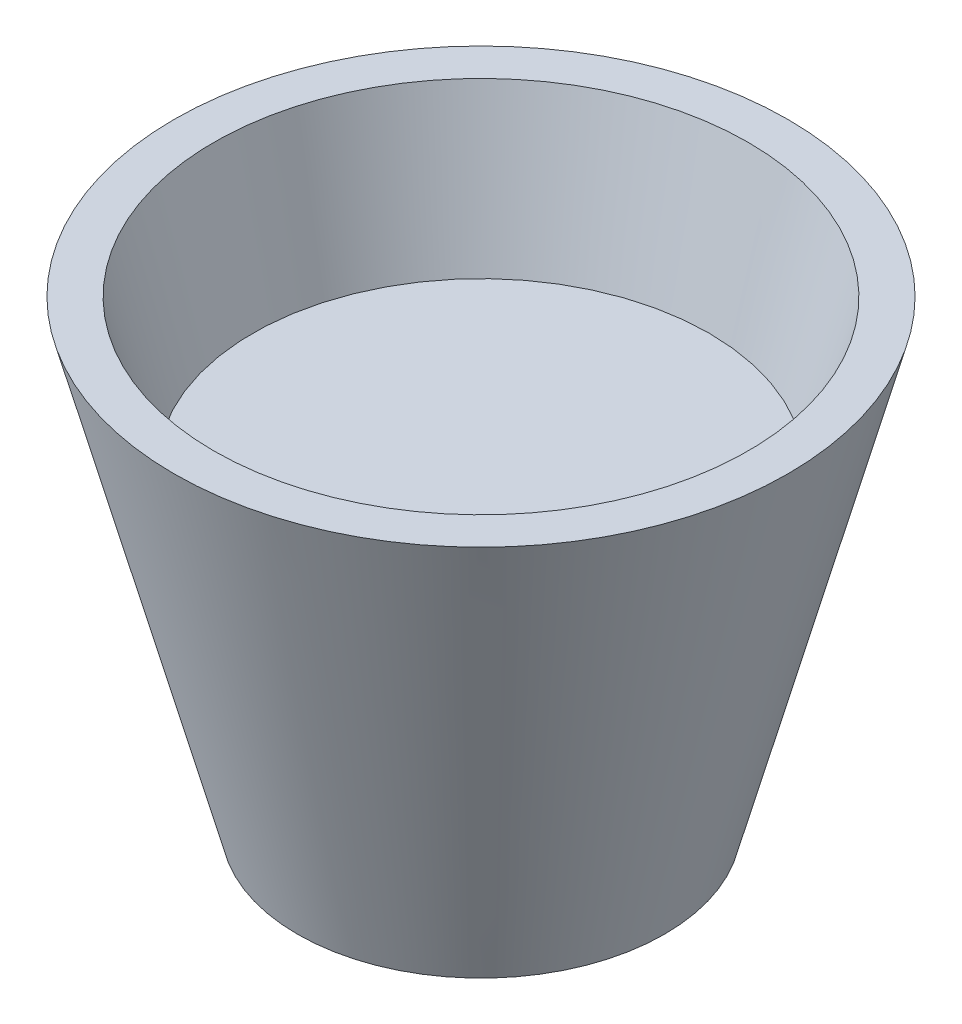
from build123d import *


with BuildPart() as part:
    # Sketch1 → Revolve1 (revolve)
    with BuildSketch(Plane.XY):
        Polygon((0, 0), (25.509745163, 0), (44.225996254, 69.85), (50.8, 69.85), (30.382271537, -6.35), (0, -6.35), align=None)
    revolve(axis=Axis((0, 0, 0), (0, 1, 0)))


with BuildPart() as body_2:
    # Sketch2 → Revolve2 (revolve)
    with BuildSketch(Plane.XY):
        Polygon((0, 0), (25.522903868, 0), (37.930961748, 45.728698118), (0, 45.728698118), align=None)
    revolve(axis=Axis((0, 0, 0), (0, 1, 0)))


solid = Compound([part.part, body_2.part])
